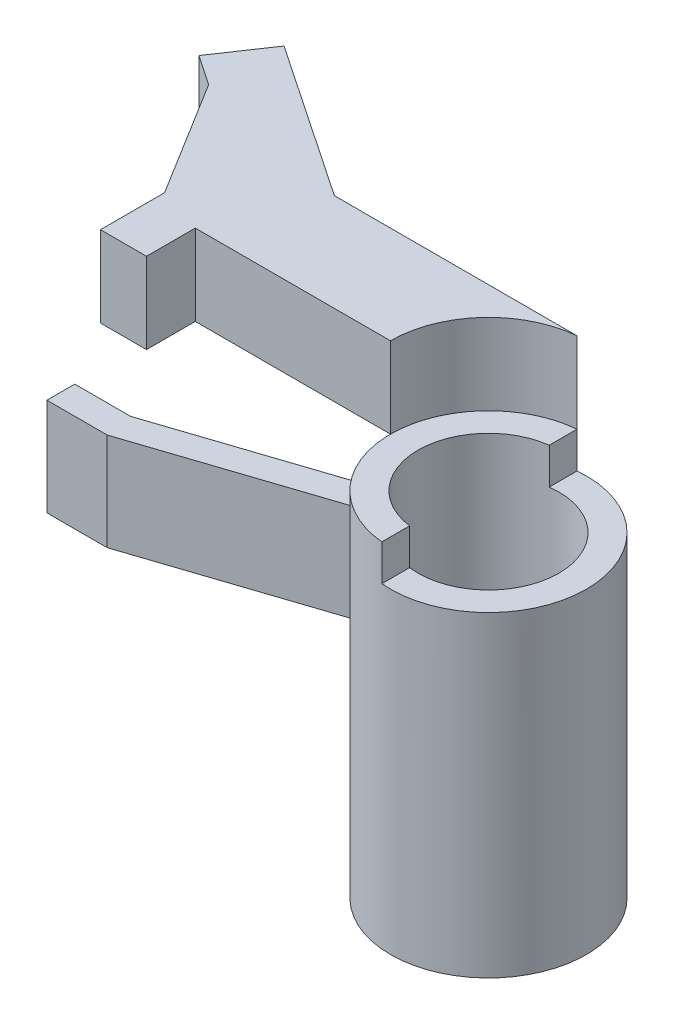
from build123d import *

# Parameters (mm, degrees)
SKETCH1_R           = 3.515
SKETCH1_R_2         = 2.525
BOSS_EXTRUDE1_DEPTH = 11.35
BOSS_EXTRUDE2_DEPTH = 1.3
BOSS_EXTRUDE3_DEPTH = 2.9
BOSS_EXTRUDE4_DEPTH = 3.5


with BuildPart() as part:
    # Sketch1 → Boss-Extrude1 (new body)
    with BuildSketch(Plane(origin=(0, 0, 0), x_dir=(1, 0, 0), z_dir=(0, 1, 0))):
        Circle(SKETCH1_R)
        Circle(SKETCH1_R_2, mode=Mode.SUBTRACT)
    extrude(amount=BOSS_EXTRUDE1_DEPTH)

    # Sketch2 → Boss-Extrude2 (add)
    with BuildSketch(Plane(origin=(0, 11.35, 0), x_dir=(1, 0, 0), z_dir=(0, 1, 0))):
        with BuildLine():
            Line((-0.324384032, 3.5), (-0.324384032, 2.504076676))
            ThreePointArc((-0.324384032, 2.504076676), (-2.525, 0), (-0.324384032, -2.504076676))
            Line((-0.324384032, -2.504076676), (-0.324384032, -3.5))
            ThreePointArc((-0.324384032, -3.5), (-3.515, 0), (-0.324384032, 3.5))
        make_face()
    extrude(amount=BOSS_EXTRUDE2_DEPTH)

    # Sketch6 → Boss-Extrude4 (add)
    with BuildSketch(Plane(origin=(0, 11.65, 0), x_dir=(1, 0, 0), z_dir=(0, 1, 0))):
        with BuildLine():
            Line((-3.369751475, -1), (-9.729692569, -3.107403444))
            Line((-9.729692569, -3.107403444), (-11.729692569, -3.107403444))
            Line((-11.729692569, -3.107403444), (-11.729692569, -4.105940644))
            Line((-11.729692569, -4.105940644), (-9.568328637, -4.107403444))
            Line((-9.568328637, -4.107403444), (-2.948307108, -1.913820837))
            ThreePointArc((-2.948307108, -1.913820837), (-3.191901188, -1.472070584), (-3.369751475, -1))
        make_face()
    extrude(amount=-BOSS_EXTRUDE4_DEPTH)


with BuildPart() as body_2:
    # Sketch3 → Boss-Extrude3 (new body)
    with BuildSketch(Plane(origin=(0, 12.65, 0), x_dir=(1, 0, 0), z_dir=(0, 1, 0))):
        with BuildLine():
            Line((-0.324384032, 3.5), (-9.024384032, 3.5))
            Line((-9.024384032, 3.5), (-14.578935768, 7.246592453))
            Line((-14.578935768, 7.246592453), (-15.809160155, 5.422709794))
            Line((-15.809160155, 5.422709794), (-14.731411311, 4.695759019))
            Line((-14.731411311, 4.695759019), (-12.165, 0.55))
            Line((-12.165, 0.55), (-12.165, -1.75))
            Line((-12.165, -1.75), (-10.515, -1.75))
            Line((-10.515, -1.75), (-10.515, 0))
            Line((-10.515, 0), (-3.515, 0))
            ThreePointArc((-3.515, 0), (-2.597636894, 2.368017644), (-0.324384032, 3.5))
        make_face()
    extrude(amount=BOSS_EXTRUDE3_DEPTH)


solid = Compound([part.part, body_2.part])
